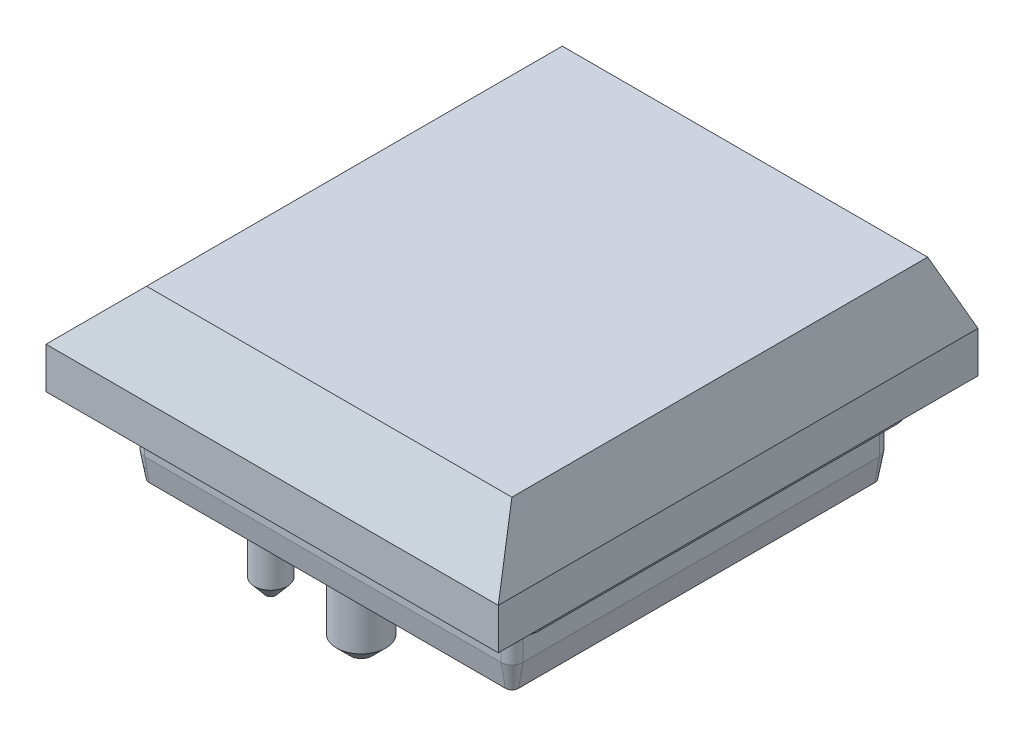
from build123d import *

# Parameters (mm, degrees)
BOSS_EXTRUDE1_DEPTH   = 0.8
BOSS_EXTRUDE2_DEPTH   = 1.3
BOSS_EXTRUDE3_DEPTH   = 0.9
BOSS_EXTRUDE3_TAPER   = 10
SKETCH4_R             = 1.6
SKETCH4_R_2           = 0.9
BOSS_EXTRUDE4_DEPTH   = 2.65
SKETCH5_R             = 0.6
BOSS_EXTRUDE5_DEPTH   = 3
CHAMFER1_SIZE         = 0.5
CHAMFER1_SIZE2        = 0.419549816
CHAMFER1_PART_2_SIZE  = 0.5
CHAMFER1_PART_2_SIZE2 = 0.419549816
CHAMFER1_PART_3_SIZE  = 0.5
CHAMFER1_PART_3_SIZE2 = 0.419549816
CHAMFER2_SIZE         = 0.5
SKETCH6_W             = 16.5
SKETCH6_H             = 17.5
BOSS_EXTRUDE6_DEPTH   = 4
CHAMFER3_SIZE         = 2.5
CHAMFER3_SIZE2        = 0.669872981
CHAMFER4_SIZE         = 2.5
CHAMFER4_SIZE2        = 1.165769145
CHAMFER4_PART_2_SIZE  = 2.5
CHAMFER4_PART_2_SIZE2 = 1.165769145
CHAMFER5_SIZE         = 2.5


with BuildPart() as part:
    # Sketch1 → Boss-Extrude1 (new body)
    with BuildSketch(Plane(origin=(0, 0, 0), x_dir=(1, 0, 0), z_dir=(0, 1, 0))):
        with BuildLine():
            Line((-6.5, -7.5), (6.5, -7.5))
            ThreePointArc((6.5, -7.5), (7.207106781, -7.207106781), (7.5, -6.5))
            Line((7.5, -6.5), (7.5, 6.5))
            ThreePointArc((7.5, 6.5), (7.207106781, 7.207106781), (6.5, 7.5))
            Line((6.5, 7.5), (-6.5, 7.5))
            ThreePointArc((-6.5, 7.5), (-7.207106781, 7.207106781), (-7.5, 6.5))
            Line((-7.5, 6.5), (-7.5, -6.5))
            ThreePointArc((-7.5, -6.5), (-7.207106781, -7.207106781), (-6.5, -7.5))
        make_face()
    extrude(amount=BOSS_EXTRUDE1_DEPTH)

    # Sketch2 → Boss-Extrude2 (add)
    with BuildSketch(Plane.XZ):
        with BuildLine():
            Line((-6.9, 6.5), (-6.9, -6.5))
            ThreePointArc((-6.9, -6.5), (-6.782842712, -6.782842712), (-6.5, -6.9))
            Line((-6.5, -6.9), (6.5, -6.9))
            ThreePointArc((6.5, -6.9), (6.782842712, -6.782842712), (6.9, -6.5))
            Line((6.9, -6.5), (6.9, 6.5))
            ThreePointArc((6.9, 6.5), (6.782842712, 6.782842712), (6.5, 6.9))
            Line((6.5, 6.9), (-6.5, 6.9))
            ThreePointArc((-6.5, 6.9), (-6.782842712, 6.782842712), (-6.9, 6.5))
        make_face()
    extrude(amount=BOSS_EXTRUDE2_DEPTH)

    # Sketch3 → Boss-Extrude3 (add)
    with BuildSketch(Plane.XZ.offset(1.3)):
        with BuildLine():
            Line((-6.9, 6.5), (-6.9, -6.5))
            ThreePointArc((-6.9, -6.5), (-6.782842712, -6.782842712), (-6.5, -6.9))
            Line((-6.5, -6.9), (6.5, -6.9))
            ThreePointArc((6.5, -6.9), (6.782842712, -6.782842712), (6.9, -6.5))
            Line((6.9, -6.5), (6.9, 6.5))
            ThreePointArc((6.9, 6.5), (6.782842712, 6.782842712), (6.5, 6.9))
            Line((6.5, 6.9), (-6.5, 6.9))
            ThreePointArc((-6.5, 6.9), (-6.782842712, 6.782842712), (-6.9, 6.5))
        make_face()
    extrude(amount=BOSS_EXTRUDE3_DEPTH, taper=BOSS_EXTRUDE3_TAPER)

    # Sketch4 → Boss-Extrude4 (add)
    with BuildSketch(Plane.XZ.offset(2.2)):
        Circle(SKETCH4_R)
        with Locations((0, -5.5)):
            Circle(SKETCH4_R_2)
        with Locations((0, 5.5)):
            Circle(SKETCH4_R_2)
    extrude(amount=BOSS_EXTRUDE4_DEPTH)

    # Sketch5 → Boss-Extrude5 (add)
    with BuildSketch(Plane.XZ.offset(2.2)):
        with Locations((-5.9, 0)):
            Circle(SKETCH5_R)
        with Locations((-3.8, -5)):
            Circle(SKETCH5_R)
        with Locations((-3.8, 5)):
            Circle(SKETCH5_R)
    extrude(amount=BOSS_EXTRUDE5_DEPTH)

    # Chamfer1
    chamfer1_edges = [part.edges().sort_by_distance(p)[0] for p in [
        (-6.5, -5.2, 0),
    ]]
    chamfer1_side = [part.faces().sort_by_distance(p)[0] for p in [
        (-6.5, -3.7, 0),
    ]]
    chamfer(chamfer1_edges, length=CHAMFER1_SIZE, length2=CHAMFER1_SIZE2, reference=chamfer1_side[0])

    # Chamfer1 part 2
    chamfer1_part_2_edges = [part.edges().sort_by_distance(p)[0] for p in [
        (-4.4, -5.2, -5),
    ]]
    chamfer1_part_2_side = [part.faces().sort_by_distance(p)[0] for p in [
        (-4.4, -3.7, -5),
    ]]
    chamfer(chamfer1_part_2_edges, length=CHAMFER1_PART_2_SIZE, length2=CHAMFER1_PART_2_SIZE2, reference=chamfer1_part_2_side[0])

    # Chamfer1 part 3
    chamfer1_part_3_edges = [part.edges().sort_by_distance(p)[0] for p in [
        (-4.4, -5.2, 5),
    ]]
    chamfer1_part_3_side = [part.faces().sort_by_distance(p)[0] for p in [
        (-4.4, -3.7, 5),
    ]]
    chamfer(chamfer1_part_3_edges, length=CHAMFER1_PART_3_SIZE, length2=CHAMFER1_PART_3_SIZE2, reference=chamfer1_part_3_side[0])

    # Chamfer2
    chamfer2_edges = [part.edges().sort_by_distance(p)[0] for p in [
        (-1.6, -4.85, 0),
        (-0.9, -4.85, -5.5),
        (-0.9, -4.85, 5.5),
    ]]
    chamfer(chamfer2_edges, length=CHAMFER2_SIZE)

    # Sketch6 → Boss-Extrude6 (add)
    with BuildSketch(Plane(origin=(0, 0.8, 0), x_dir=(1, 0, 0), z_dir=(0, 1, 0))):
        Rectangle(SKETCH6_W, SKETCH6_H)
    extrude(amount=BOSS_EXTRUDE6_DEPTH)

    # Chamfer3
    chamfer3_edges = [part.edges().sort_by_distance(p)[0] for p in [
        (8.25, 4.8, 0),
    ]]
    chamfer3_side = [part.faces().sort_by_distance(p)[0] for p in [
        (8.25, 2.8, 0),
    ]]
    chamfer(chamfer3_edges, length=CHAMFER3_SIZE, length2=CHAMFER3_SIZE2, reference=chamfer3_side[0])

    # Chamfer4
    chamfer4_edges = [part.edges().sort_by_distance(p)[0] for p in [
        (-0.334936491, 4.8, -8.75),
    ]]
    chamfer4_side = [part.faces().sort_by_distance(p)[0] for p in [
        (-0.103143341, 2.785008314, -8.75),
    ]]
    chamfer(chamfer4_edges, length=CHAMFER4_SIZE, length2=CHAMFER4_SIZE2, reference=chamfer4_side[0])

    # Chamfer4 part 2
    chamfer4_part_2_edges = [part.edges().sort_by_distance(p)[0] for p in [
        (-0.334936491, 4.8, 8.75),
    ]]
    chamfer4_part_2_side = [part.faces().sort_by_distance(p)[0] for p in [
        (-0.103143341, 2.785008314, 8.75),
    ]]
    chamfer(chamfer4_part_2_edges, length=CHAMFER4_PART_2_SIZE, length2=CHAMFER4_PART_2_SIZE2, reference=chamfer4_part_2_side[0])

    # Chamfer5
    chamfer5_edges = [part.edges().sort_by_distance(p)[0] for p in [
        (-8.25, 4.8, 0),
    ]]
    chamfer(chamfer5_edges, length=CHAMFER5_SIZE)


solid = part.part
